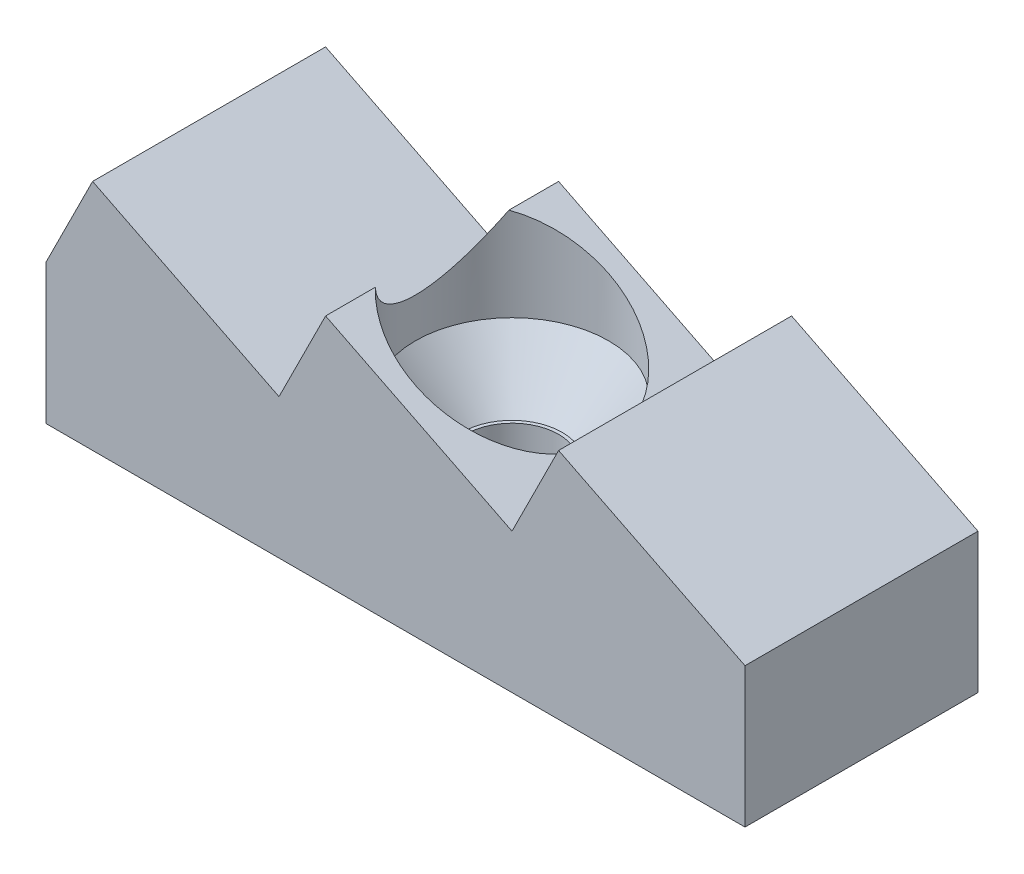
from build123d import *

# Parameters (mm, degrees)
SKETCH_1_W          = 15
SKETCH_1_H          = 5
EXTRUDE_1_DEPTH     = 3
EXTRUDE_2_DEPTH     = 2.5
SKETCH_1_3_R        = 1
CUT_EXTRUDE_1_DEPTH = 10.354143467
SKETCH_1_4_R        = 2.1
CUT_EXTRUDE_2_DEPTH = 1.4
CUT_EXTRUDE_START   = -1
SKETCH_5_R          = 2.075
CUT_EXTRUDE_3_DEPTH = 1


with BuildPart() as part:
    # 草图1 → 凸台-拉伸1 (new body)
    with BuildSketch(Plane(origin=(0, 0, 0), x_dir=(1, 0, 0), z_dir=(0, 1, 0))):
        Rectangle(SKETCH_1_W, SKETCH_1_H)
    extrude(amount=EXTRUDE_1_DEPTH)

    # 草图2 → 凸台-拉伸2 (add, symmetric)
    with BuildSketch(Plane.XY):
        Polygon((2.5, 3), (7.5, 3), (3.5, 5), align=None)
        Polygon((-7.5, 3), (-2.5, 3), (-6.5, 5), align=None)
        Polygon((-2.5, 3), (2.5, 3), (-1.5, 5), align=None)
    extrude(amount=EXTRUDE_2_DEPTH, both=True)

    # 草图1<3> → 切除-拉伸1 (cut, through all)
    with BuildSketch(Plane(origin=(0, 0, 0), x_dir=(1, 0, 0), z_dir=(0, 1, 0))):
        Circle(SKETCH_1_3_R)
    extrude(amount=CUT_EXTRUDE_1_DEPTH, mode=Mode.SUBTRACT)

    # 草图1<4> → 切除-拉伸2 (cut)
    with BuildSketch(Plane(origin=(0, 0, 0), x_dir=(1, 0, 0), z_dir=(0, 1, 0))):
        with Locations((5, 0)):
            Circle(SKETCH_1_4_R)
        with Locations((-5, 0)):
            Circle(SKETCH_1_4_R)
    extrude(amount=CUT_EXTRUDE_2_DEPTH, mode=Mode.SUBTRACT)

    # 草图4 → 切除-旋转1 (revolve, cut)
    with BuildSketch(Plane.XY):
        Polygon((0, 1.8), (1.075, 1.8), (2.075, 3), (2.075, 5), (0, 5), align=None)
    revolve(axis=Axis((0, 0, 0), (0, 1, 0)), mode=Mode.SUBTRACT)

    # 草图5 → 切除-拉伸3 (cut)
    with BuildSketch(Plane.XZ.offset(CUT_EXTRUDE_START)):
        Circle(SKETCH_5_R)
    extrude(amount=CUT_EXTRUDE_3_DEPTH, mode=Mode.SUBTRACT)


solid = part.part
